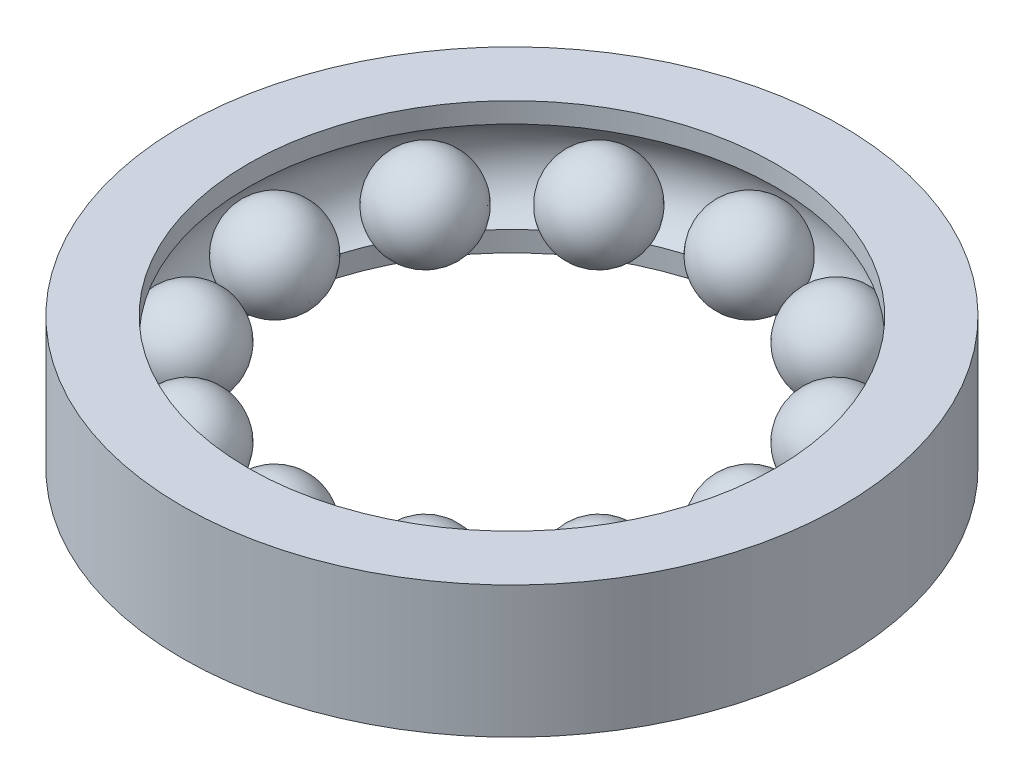
from build123d import *


with BuildPart() as part:
    # Çizim1 → Döndür1 (revolve)
    with BuildSketch(Plane.XY):
        with BuildLine():
            Line((2, 0.5), (2, 0.346410162))
            ThreePointArc((2, 0.346410162), (2.2, 0), (2, -0.346410162))
            Line((2, -0.346410162), (2, -0.5))
            Line((2, -0.5), (2.5, -0.5))
            Line((2.5, -0.5), (2.5, 0.5))
            Line((2.5, 0.5), (2, 0.5))
        make_face()
    revolve(axis=Axis((0, 0.5, 0), (0, -1, 0)))


with BuildPart() as body_2:
    # Çizim3 → Döndür3 (revolve)
    with BuildSketch(Plane(origin=(0, 0, 0), x_dir=(1, 0, 0), z_dir=(0, 1, 0))):
        with BuildLine():
            Line((1.8, 0.35), (1.8, -0.35))
            ThreePointArc((1.8, -0.35), (2.15, 0), (1.8, 0.35))
        make_face()
    revolve(axis=Axis((1.8, 0, -0.35), (0, 0, 1)))


with BuildPart() as body_3:
    # Çizim4 → Döndür4 (revolve)
    with BuildSketch(Plane(origin=(0, 0, 0), x_dir=(1, 0, 0), z_dir=(0, 1, 0))):
        with BuildLine():
            Line((1.558845727, 1.25), (1.558845727, 0.55))
            ThreePointArc((1.558845727, 0.55), (1.908845727, 0.9), (1.558845727, 1.25))
        make_face()
    revolve(axis=Axis((1.558845727, 0, -1.25), (0, 0, 1)))


with BuildPart() as body_4:
    # Çizim5 → Döndür5 (revolve)
    with BuildSketch(Plane(origin=(0, 0, 0), x_dir=(1, 0, 0), z_dir=(0, 1, 0))):
        with BuildLine():
            Line((0.9, 1.908845727), (0.9, 1.208845727))
            ThreePointArc((0.9, 1.208845727), (1.25, 1.558845727), (0.9, 1.908845727))
        make_face()
    revolve(axis=Axis((0.9, 0, -1.908845727), (0, 0, 1)))


with BuildPart() as body_5:
    # Çizim6 → Döndür6 (revolve)
    with BuildSketch(Plane(origin=(0, 0, 0), x_dir=(1, 0, 0), z_dir=(0, 1, 0))):
        with BuildLine():
            Line((0, 2.15), (0, 1.45))
            ThreePointArc((0, 1.45), (0.35, 1.8), (0, 2.15))
        make_face()
    revolve(axis=Axis((0, 0, 0), (0, 0, -1)))


with BuildPart() as body_6:
    # Çizim7 → Döndür7 (revolve)
    with BuildSketch(Plane(origin=(0, 0, 0), x_dir=(1, 0, 0), z_dir=(0, 1, 0))):
        with BuildLine():
            Line((-0.9, 1.908845727), (-0.9, 1.208845727))
            ThreePointArc((-0.9, 1.208845727), (-0.55, 1.558845727), (-0.9, 1.908845727))
        make_face()
    revolve(axis=Axis((-0.9, 0, -1.908845727), (0, 0, 1)))


with BuildPart() as body_7:
    # Çizim8 → Döndür8 (revolve)
    with BuildSketch(Plane(origin=(0, 0, 0), x_dir=(1, 0, 0), z_dir=(0, 1, 0))):
        with BuildLine():
            Line((-1.558845727, 1.25), (-1.558845727, 0.55))
            ThreePointArc((-1.558845727, 0.55), (-1.208845727, 0.9), (-1.558845727, 1.25))
        make_face()
    revolve(axis=Axis((-1.558845727, 0, -1.25), (0, 0, 1)))


with BuildPart() as body_8:
    # Çizim9 → Döndür9 (revolve)
    with BuildSketch(Plane(origin=(0, 0, 0), x_dir=(1, 0, 0), z_dir=(0, 1, 0))):
        with BuildLine():
            Line((-1.8, 0.35), (-1.8, -0.35))
            ThreePointArc((-1.8, -0.35), (-1.45, 0), (-1.8, 0.35))
        make_face()
    revolve(axis=Axis((-1.8, 0, -0.35), (0, 0, 1)))


with BuildPart() as body_9:
    # Çizim10 → Döndür10 (revolve)
    with BuildSketch(Plane(origin=(0, 0, 0), x_dir=(1, 0, 0), z_dir=(0, 1, 0))):
        with BuildLine():
            Line((-1.558845727, -0.55), (-1.558845727, -1.25))
            ThreePointArc((-1.558845727, -1.25), (-1.208845727, -0.9), (-1.558845727, -0.55))
        make_face()
    revolve(axis=Axis((-1.558845727, 0, 0.55), (0, 0, 1)))


with BuildPart() as body_10:
    # Çizim11 → Döndür11 (revolve)
    with BuildSketch(Plane(origin=(0, 0, 0), x_dir=(1, 0, 0), z_dir=(0, 1, 0))):
        with BuildLine():
            Line((-0.9, -1.208845727), (-0.9, -1.908845727))
            ThreePointArc((-0.9, -1.908845727), (-0.55, -1.558845727), (-0.9, -1.208845727))
        make_face()
    revolve(axis=Axis((-0.9, 0, 1.208845727), (0, 0, 1)))


with BuildPart() as body_11:
    # Çizim12 → Döndür12 (revolve)
    with BuildSketch(Plane(origin=(0, 0, 0), x_dir=(1, 0, 0), z_dir=(0, 1, 0))):
        with BuildLine():
            Line((0, -1.45), (0, -2.15))
            ThreePointArc((0, -2.15), (0.35, -1.8), (0, -1.45))
        make_face()
    revolve(axis=Axis((0, 0, 1.45), (0, 0, 1)))


with BuildPart() as body_12:
    # Çizim13 → Döndür13 (revolve)
    with BuildSketch(Plane(origin=(0, 0, 0), x_dir=(1, 0, 0), z_dir=(0, 1, 0))):
        with BuildLine():
            Line((0.9, -1.208845727), (0.9, -1.908845727))
            ThreePointArc((0.9, -1.908845727), (1.25, -1.558845727), (0.9, -1.208845727))
        make_face()
    revolve(axis=Axis((0.9, 0, 1.208845727), (0, 0, 1)))


with BuildPart() as body_13:
    # Çizim14 → Döndür14 (revolve)
    with BuildSketch(Plane(origin=(0, 0, 0), x_dir=(1, 0, 0), z_dir=(0, 1, 0))):
        with BuildLine():
            Line((1.558845727, -0.55), (1.558845727, -1.25))
            ThreePointArc((1.558845727, -1.25), (1.908845727, -0.9), (1.558845727, -0.55))
        make_face()
    revolve(axis=Axis((1.558845727, 0, 0.55), (0, 0, 1)))


solid = Compound([part.part, body_2.part, body_3.part, body_4.part, body_5.part, body_6.part, body_7.part, body_8.part, body_9.part, body_10.part, body_11.part, body_12.part, body_13.part])
